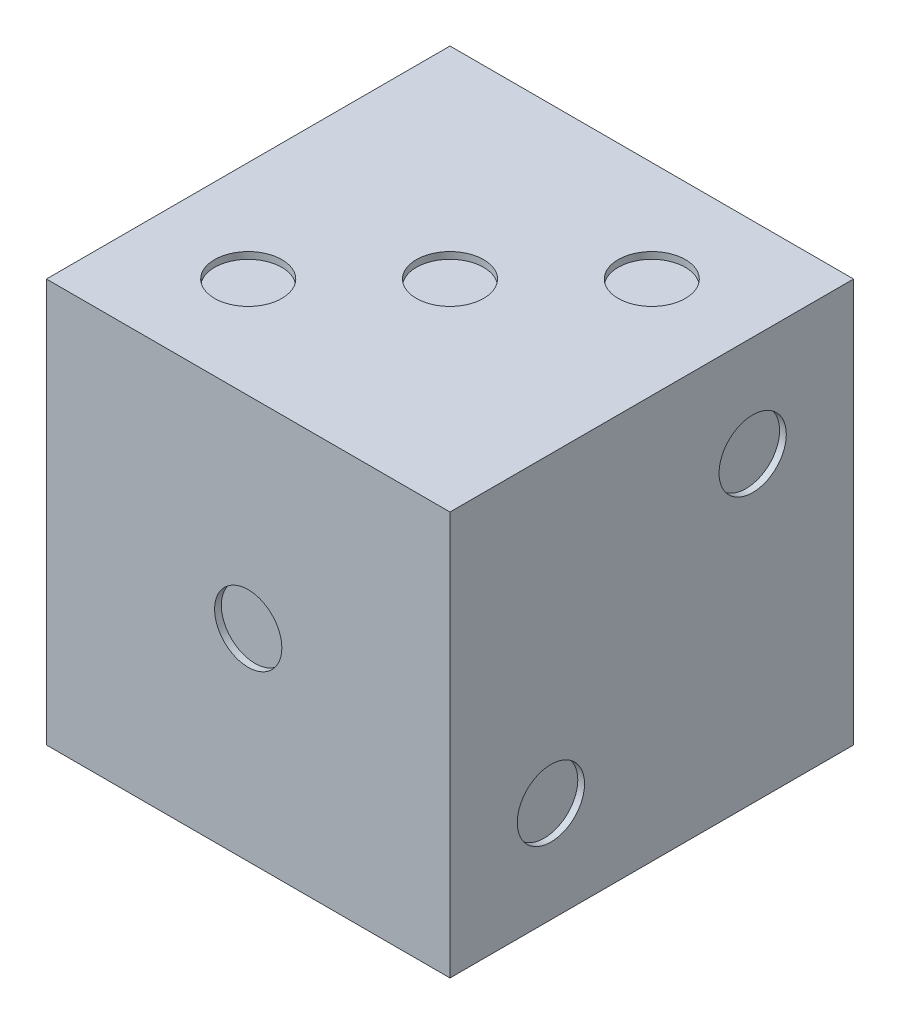
from build123d import *

# Parameters (mm, degrees)
SKETCH1_W          = 60
SKETCH1_H          = 60
EXTRUDE1_DEPTH     = 60
SKETCH2_R          = 5
CUT_EXTRUDE1_DEPTH = 1
SKETCH3_R          = 5
CUT_EXTRUDE2_DEPTH = 1
SKETCH4_R          = 5
CUT_EXTRUDE3_DEPTH = 1
SKETCH5_R          = 5
CUT_EXTRUDE4_DEPTH = 1
SKETCH6_R          = 5
CUT_EXTRUDE5_DEPTH = 1
SKETCH7_R          = 5
CUT_EXTRUDE6_DEPTH = 1


with BuildPart() as part:
    # Sketch1 → Extrude1 (new body)
    with BuildSketch(Plane(origin=(0, 0, 0), x_dir=(1, 0, 0), z_dir=(0, 1, 0))):
        with Locations((30, 30)):
            Rectangle(SKETCH1_W, SKETCH1_H)
    extrude(amount=EXTRUDE1_DEPTH)

    # Sketch2 → Cut-Extrude1 (cut)
    with BuildSketch(Plane(origin=(0, 60, 0), x_dir=(-1, 0, 0), z_dir=(0, 1, 0))):
        with Locations(Location((-45, -45, 0), (0, 0, 90))):  # turned: the seam where the file's is
            Circle(SKETCH2_R)
        with Locations(Location((-30, -30, 0), (0, 0, 90))):  # turned: the seam where the file's is
            Circle(SKETCH2_R)
        with Locations(Location((-15, -15, 0), (0, 0, 90))):  # turned: the seam where the file's is
            Circle(SKETCH2_R)
    extrude(amount=-CUT_EXTRUDE1_DEPTH, mode=Mode.SUBTRACT)

    # Sketch3 → Cut-Extrude2 (cut)
    with BuildSketch(Plane(origin=(60, 0, 0), x_dir=(0, 0, -1), z_dir=(1, 0, 0))):
        with Locations((45, 45)):
            Circle(SKETCH3_R)
        with Locations((15, 15)):
            Circle(SKETCH3_R)
    extrude(amount=-CUT_EXTRUDE2_DEPTH, mode=Mode.SUBTRACT)

    # Sketch4 → Cut-Extrude3 (cut)
    with BuildSketch(Plane.XY):
        with Locations((30, 30)):
            Circle(SKETCH4_R)
    extrude(amount=-CUT_EXTRUDE3_DEPTH, mode=Mode.SUBTRACT)

    # Sketch5 → Cut-Extrude4 (cut)
    with BuildSketch(Plane(origin=(0, 0, -60), x_dir=(-1, 0, 0), z_dir=(0, 0, -1))):
        with Locations((-15, 45)):
            Circle(SKETCH5_R)
        with Locations((-15, 30)):
            Circle(SKETCH5_R)
        with Locations((-15, 15)):
            Circle(SKETCH5_R)
        with Locations((-45, 45)):
            Circle(SKETCH5_R)
        with Locations((-45, 30)):
            Circle(SKETCH5_R)
        with Locations((-45, 15)):
            Circle(SKETCH5_R)
    extrude(amount=-CUT_EXTRUDE4_DEPTH, mode=Mode.SUBTRACT)

    # Sketch6 → Cut-Extrude5 (cut)
    with BuildSketch(Plane.ZY):
        with Locations((-30, 30)):
            Circle(SKETCH6_R)
        with Locations(Location((-45, 45, 0), (0, 0, 180))):  # turned: the seam where the file's is
            Circle(SKETCH6_R)
        with Locations((-15, 45)):
            Circle(SKETCH6_R)
        with Locations((-45, 15)):
            Circle(SKETCH6_R)
        with Locations(Location((-15, 15, 0), (0, 0, 180))):  # turned: the seam where the file's is
            Circle(SKETCH6_R)
    extrude(amount=-CUT_EXTRUDE5_DEPTH, mode=Mode.SUBTRACT)

    # Sketch7 → Cut-Extrude6 (cut)
    with BuildSketch(Plane.XZ):
        with Locations(Location((15, -45, 0), (0, 0, 270))):  # turned: the seam where the file's is
            Circle(SKETCH7_R)
        with Locations(Location((15, -15, 0), (0, 0, 90))):  # turned: the seam where the file's is
            Circle(SKETCH7_R)
        with Locations(Location((45, -45, 0), (0, 0, 90))):  # turned: the seam where the file's is
            Circle(SKETCH7_R)
        with Locations(Location((45, -15, 0), (0, 0, 270))):  # turned: the seam where the file's is
            Circle(SKETCH7_R)
    extrude(amount=-CUT_EXTRUDE6_DEPTH, mode=Mode.SUBTRACT)


solid = part.part
